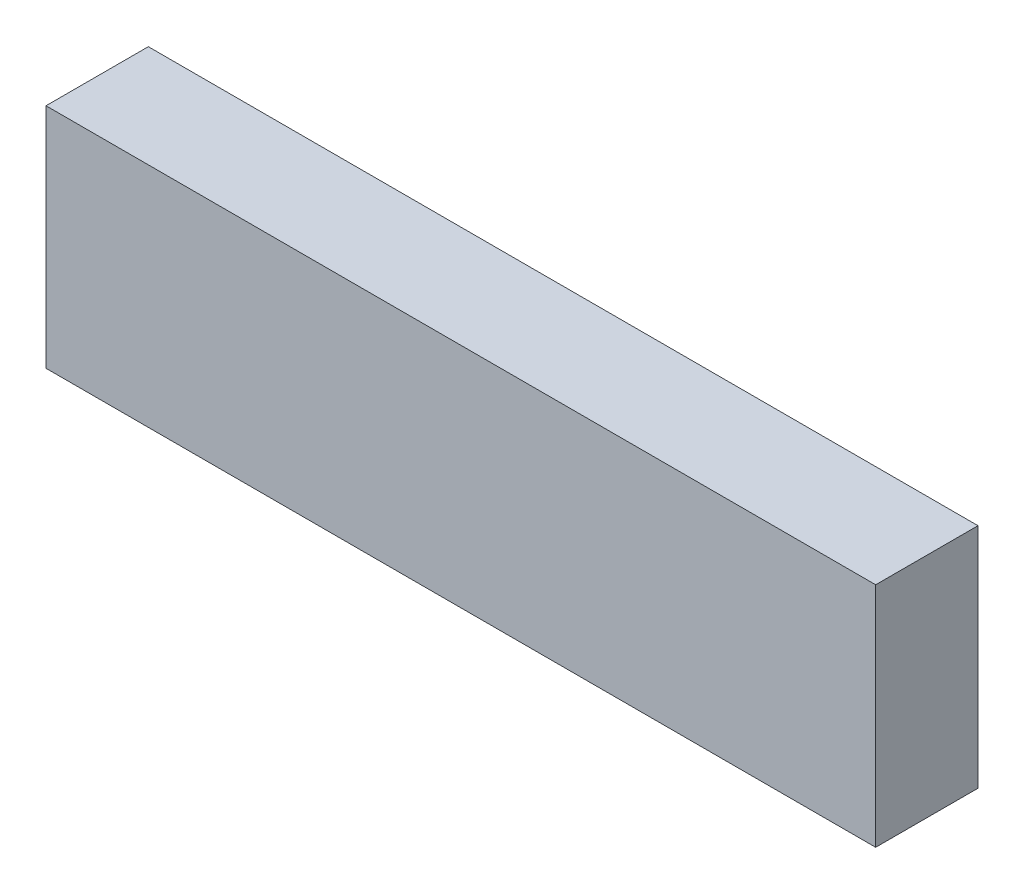
from build123d import *

# Parameters (mm, degrees)
SKETCH1_W           = 1.5
SKETCH1_H           = 0.411111111
BOSS_EXTRUDE1_DEPTH = 0.185


with BuildPart() as part:
    # Sketch1 → Boss-Extrude1 (new body)
    with BuildSketch(Plane.XY):
        with Locations((0.75, 0.205555556)):
            Rectangle(SKETCH1_W, SKETCH1_H)
    extrude(amount=BOSS_EXTRUDE1_DEPTH)


solid = part.part
